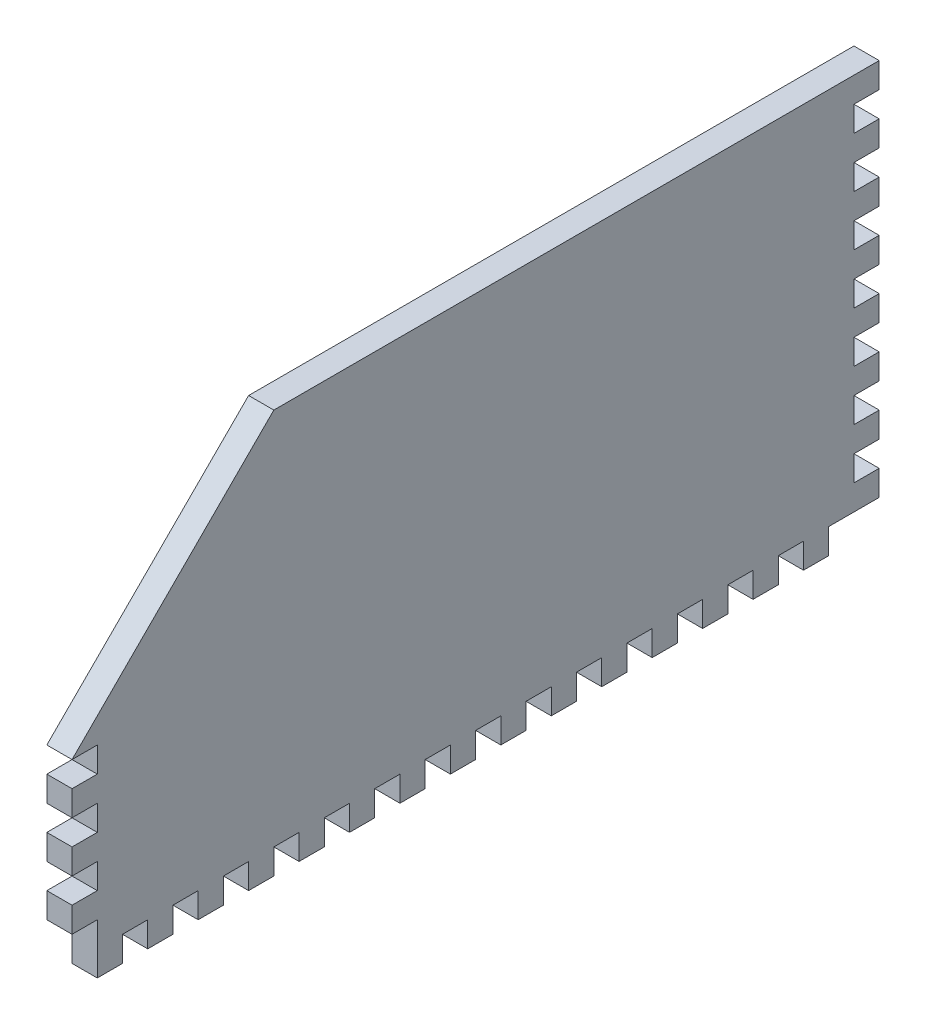
from build123d import *

# Parameters (mm, degrees)
SKETCH1_W           = 203.2
SKETCH1_H           = 101.6
BOSS_EXTRUDE1_DEPTH = 6.35
SKETCH2_W           = 6.35
SKETCH2_H           = 12.7
CUT_EXTRUDE1_DEPTH  = 6.35
SKETCH5_W           = 6.35
SKETCH5_H           = 6.35
CUT_EXTRUDE2_DEPTH  = 6.35
LPATTERN1_COUNT     = 15
LPATTERN1_PITCH     = 12.7
SKETCH6_W           = 6.35
SKETCH6_H           = 6.35
CUT_EXTRUDE3_DEPTH  = 6.35
LPATTERN2_COUNT     = 7
LPATTERN2_PITCH     = 12.7
CUT_EXTRUDE4_DEPTH  = 6.35
SKETCH8_W           = 6.35
SKETCH8_H           = 6.35
CUT_EXTRUDE5_DEPTH  = 6.35
SKETCH10_W          = 6.35
SKETCH10_H          = 6.35
CUT_EXTRUDE6_DEPTH  = 6.35
LPATTERN3_COUNT     = 3
LPATTERN3_PITCH     = 12.7


with BuildPart() as part:
    # Sketch1 → Boss-Extrude1 (new body)
    with BuildSketch(Plane(origin=(0, 0, 0), x_dir=(0, 0, -1), z_dir=(1, 0, 0))):
        with Locations((101.6, 50.8)):
            Rectangle(SKETCH1_W, SKETCH1_H)
    extrude(amount=-BOSS_EXTRUDE1_DEPTH)

    # Sketch2 → Cut-Extrude1 (cut)
    with BuildSketch(Plane.XZ):
        with Locations((-3.175, -196.85)):
            Rectangle(SKETCH2_W, SKETCH2_H)
    extrude(amount=-CUT_EXTRUDE1_DEPTH, mode=Mode.SUBTRACT)

    # Sketch5 → Cut-Extrude2 (cut)
    with BuildSketch(Plane.XZ):
        with Locations((-3.175, -180.975)):
            Rectangle(SKETCH5_W, SKETCH5_H)
    cut_extrude2 = extrude(amount=-CUT_EXTRUDE2_DEPTH, mode=Mode.SUBTRACT)

    # LPattern1: Cut-Extrude2 ×15
    with Locations(*[(0, 0, i * LPATTERN1_PITCH) for i in range(1, LPATTERN1_COUNT)]):
        add(cut_extrude2, mode=Mode.SUBTRACT)

    # Sketch6 → Cut-Extrude3 (cut)
    with BuildSketch(Plane(origin=(0, 0, -203.2), x_dir=(-1, 0, 0), z_dir=(0, 0, -1))):
        with Locations((3.175, 15.875)):
            Rectangle(SKETCH6_W, SKETCH6_H)
    cut_extrude3 = extrude(amount=-CUT_EXTRUDE3_DEPTH, mode=Mode.SUBTRACT)

    # LPattern2: Cut-Extrude3 ×7
    with Locations(*[(0, i * LPATTERN2_PITCH, 0) for i in range(1, LPATTERN2_COUNT)]):
        add(cut_extrude3, mode=Mode.SUBTRACT)

    # Sketch7 → Cut-Extrude4 (cut)
    with BuildSketch(Plane(origin=(0, 0, 0), x_dir=(0, 0, -1), z_dir=(1, 0, 0))):
        Polygon((0, 101.6), (0, 50.8), (50.8, 101.6), align=None)
    extrude(amount=-CUT_EXTRUDE4_DEPTH, mode=Mode.SUBTRACT)

    # Sketch8 → Cut-Extrude5 (cut)
    with BuildSketch(Plane.XY):
        with Locations((-3.175, 9.525)):
            Rectangle(SKETCH8_W, SKETCH8_H)
    extrude(amount=-CUT_EXTRUDE5_DEPTH, mode=Mode.SUBTRACT)

    # Sketch10 → Cut-Extrude6 (cut)
    with BuildSketch(Plane.XY):
        with Locations((-3.175, 22.225)):
            Rectangle(SKETCH10_W, SKETCH10_H)
    cut_extrude6 = extrude(amount=-CUT_EXTRUDE6_DEPTH, mode=Mode.SUBTRACT)

    # LPattern3: Cut-Extrude6 ×3
    with Locations(*[(0, i * LPATTERN3_PITCH, 0) for i in range(1, LPATTERN3_COUNT)]):
        add(cut_extrude6, mode=Mode.SUBTRACT)


solid = part.part
